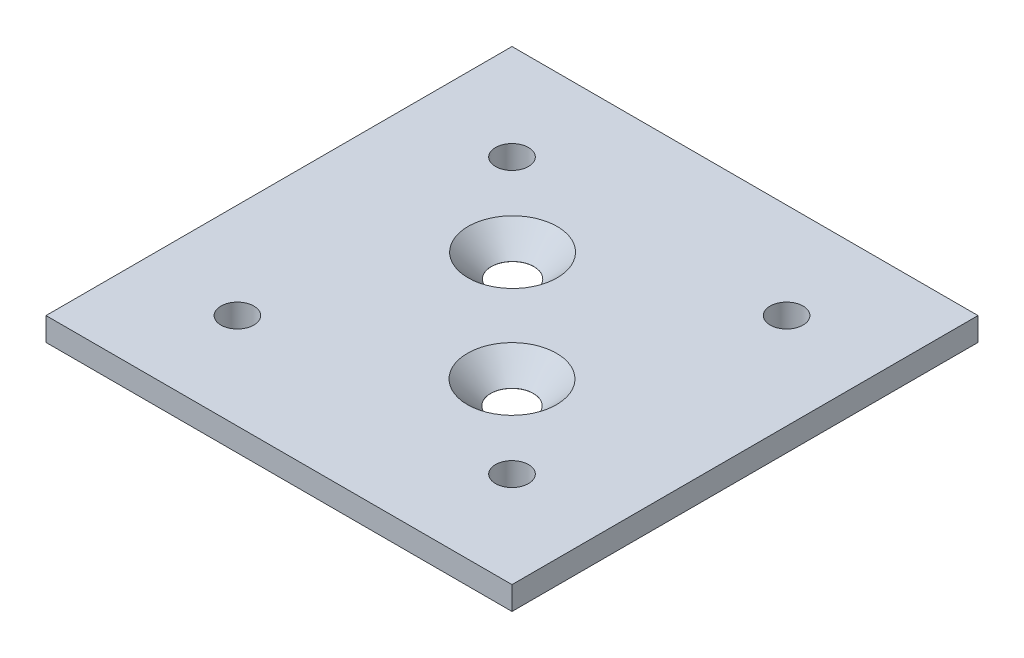
from build123d import *

# Parameters (mm, degrees)
CROQUIS1_W                                  = 60
CROQUIS1_H                                  = 60
CROQUIS1_R                                  = 2.125
CROQUIS1_R_2                                = 0.5
SALIENTE_EXTRUIR1_DEPTH                     = 3
AVELLANADO_PARA_TORNILLO_CON_CABEZA_2_COUNT = 2
AVELLANADO_PARA_TORNILLO_CON_CABEZA_2_PITCH = 19.999930309


with BuildPart() as part:
    # Croquis1 → Saliente-Extruir1 (new body)
    with BuildSketch(Plane(origin=(0, 0, 0), x_dir=(1, 0, 0), z_dir=(0, 1, 0))):
        with Locations((30, 30)):
            Rectangle(CROQUIS1_W, CROQUIS1_H)
        with Locations((12.32233047, 47.67766953)):
            Circle(CROQUIS1_R, mode=Mode.SUBTRACT)
        with Locations((12.32233047, 12.32233047)):
            Circle(CROQUIS1_R, mode=Mode.SUBTRACT)
        with Locations((47.67766953, 12.32233047)):
            Circle(CROQUIS1_R, mode=Mode.SUBTRACT)
        with Locations((47.67766953, 47.67766953)):
            Circle(CROQUIS1_R, mode=Mode.SUBTRACT)
        with Locations((22.966364616, 37.108303123)):
            Circle(CROQUIS1_R_2, mode=Mode.SUBTRACT)
        with Locations((37.071067812, 22.928932188)):
            Circle(CROQUIS1_R_2, mode=Mode.SUBTRACT)
    extrude(amount=SALIENTE_EXTRUIR1_DEPTH)

    # Croquis8 → Avellanado para tornillo con cabeza avellanada de clavija hexagonal de M53 (revolve, cut)
    with BuildSketch(Plane(origin=(22.966364616, 3, -37.108303123), x_dir=(0, 0, 1), z_dir=(1, 0, 0))):
        Polygon((0, 0), (0, 3), (2.75, 3), (2.75, 2.985), (5.735, 0), align=None)
    avellanado_para_tornillo_con_cabeza_avel = revolve(axis=Axis((22.966364616, 9.35, -37.108303123), (0, -1, 0)), mode=Mode.SUBTRACT)

    # Avellanado para tornillo con cabeza  2: Avellanado para tornillo con cabeza avellanada de clavija hexagonal de M53 ×2
    with Locations(*[Vector(0.705237617, 0, 0.708971017) * (i * AVELLANADO_PARA_TORNILLO_CON_CABEZA_2_PITCH) for i in range(1, AVELLANADO_PARA_TORNILLO_CON_CABEZA_2_COUNT)]):
        add(avellanado_para_tornillo_con_cabeza_avel, mode=Mode.SUBTRACT)


solid = part.part
